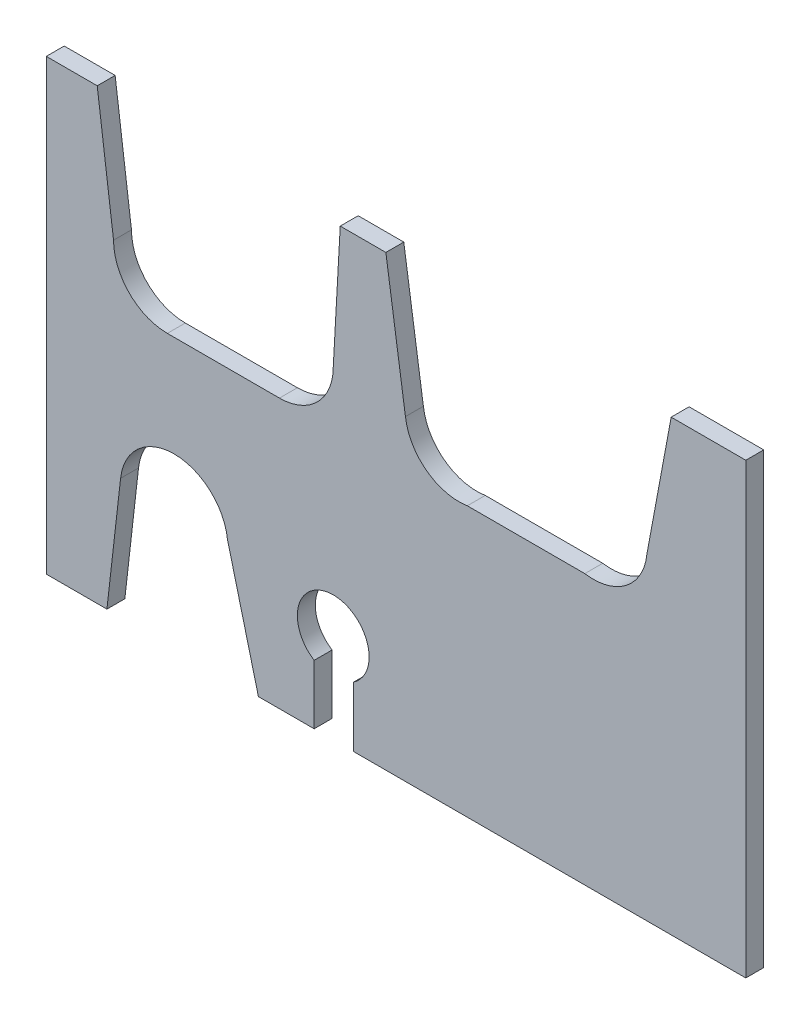
from build123d import *

# Parameters (mm, degrees)
SKETCH_1_W          = 78
SKETCH_1_H          = 50
EXTRUDE_1_DEPTH     = 2
SKETCH_2_R          = 6
SKETCH_2_R_2        = 4
CUT_EXTRUDE_2_DEPTH = 3
CUT_EXTRUDE_3_DEPTH = 3


with BuildPart() as part:
    # Эскиз1 → Бобышка-Вытянуть1 (new body)
    with BuildSketch(Plane.XY):
        with Locations((-7, 7)):
            Rectangle(SKETCH_1_W, SKETCH_1_H)
    extrude(amount=EXTRUDE_1_DEPTH)

    # Эскиз2 → Вырез-Вытянуть2 (cut, through all)
    with BuildSketch(Plane.XY.offset(2)):
        with Locations((-32.5, 18)):
            Circle(SKETCH_2_R)
        with Locations((-20, 18)):
            Circle(SKETCH_2_R)
        with Locations((0, 18)):
            Circle(SKETCH_2_R)
        with Locations((15, 18)):
            Circle(SKETCH_2_R)
        with Locations((-14, -8)):
            Circle(SKETCH_2_R_2)
        with Locations((-31.749315539, -5.262317493)):
            Circle(SKETCH_2_R)
    extrude(amount=-CUT_EXTRUDE_2_DEPTH, mode=Mode.SUBTRACT)

    # Эскиз3 → Вырез-Вытянуть3 (cut, through all)
    with BuildSketch(Plane.XY.offset(2)):
        Polygon((-37.708738379, -4.565697495), (-39.23827254, -18), (-22.345634052, -18), (-25.7898927, -4.565697495), align=None)
        Polygon((-16.128623671, -11.386585488), (-16.128623671, -18), (-11.733531884, -18), (-11.733531884, -11.295925102), align=None)
        Polygon((-40.319551463, 32), (-38.5, 18), (-32.5, 12), (-20, 12), (-14, 18), (-13.221505596, 32), align=None)
        Polygon((-8.134373627, 32), (-5.917388606, 17.007774179), (-0.949072404, 12.075537022), (15.949072404, 12.075537022), (20.784965527, 16.40809113), (23.68000723, 32), align=None)
    extrude(amount=-CUT_EXTRUDE_3_DEPTH, mode=Mode.SUBTRACT)


solid = part.part
